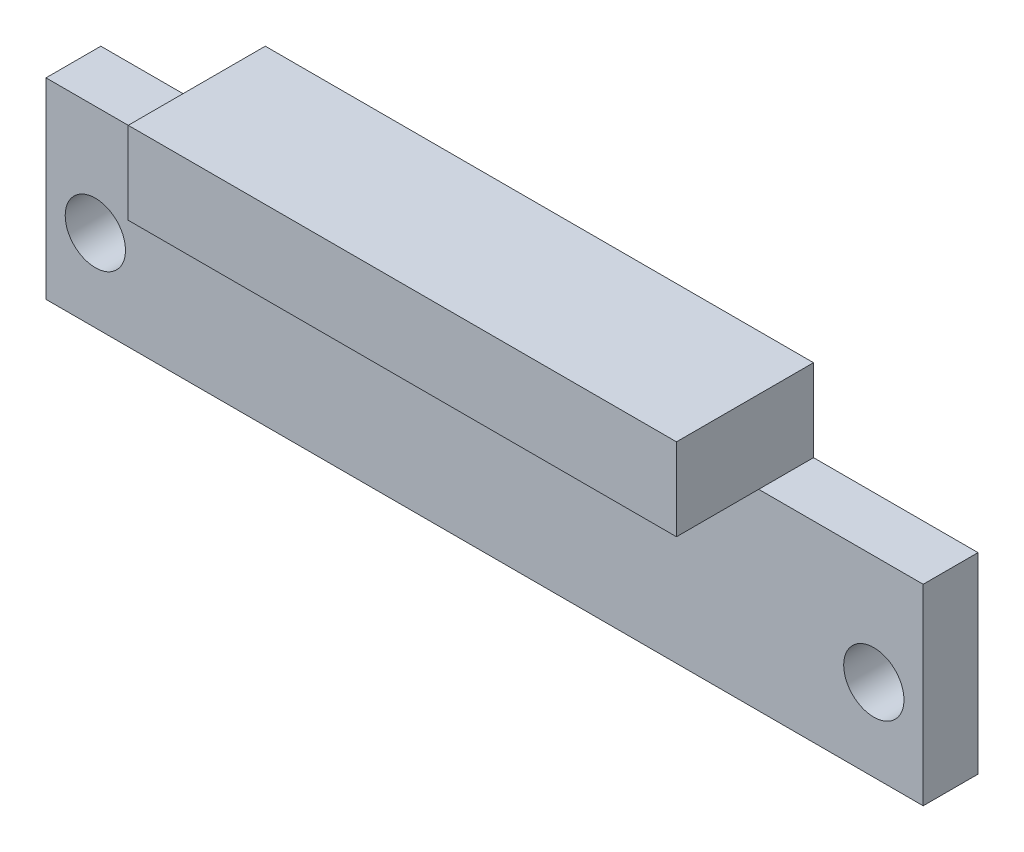
from build123d import *

# Parameters (mm, degrees)
SKETCH_1_W          = 32
SKETCH_1_H          = 7
EXTRUDE_1_DEPTH     = 2
SKETCH_2_R          = 1.1
CUT_EXTRUDE_1_DEPTH = 2
SKETCH_3_W          = 20
SKETCH_3_H          = 3
EXTRUDE_2_DEPTH     = 5


with BuildPart() as part:
    # 草图1 → 凸台-拉伸1 (new body)
    with BuildSketch(Plane.XY):
        with Locations((16, 3.5)):
            Rectangle(SKETCH_1_W, SKETCH_1_H)
    extrude(amount=EXTRUDE_1_DEPTH)

    # 草图2 → 切除-拉伸1 (cut)
    with BuildSketch(Plane(origin=(0, 0, 0), x_dir=(-1, 0, 0), z_dir=(0, 0, -1))):
        with Locations((-30.2, 3)):
            Circle(SKETCH_2_R)
        with Locations((-1.8, 3)):
            Circle(SKETCH_2_R)
    extrude(amount=-CUT_EXTRUDE_1_DEPTH, mode=Mode.SUBTRACT)

    # 草图3 → 凸台-拉伸2 (add)
    with BuildSketch(Plane(origin=(0, 0, 0), x_dir=(-1, 0, 0), z_dir=(0, 0, -1))):
        with Locations((-16, 8.5)):
            Rectangle(SKETCH_3_W, SKETCH_3_H)
    extrude(amount=-EXTRUDE_2_DEPTH)


solid = part.part
